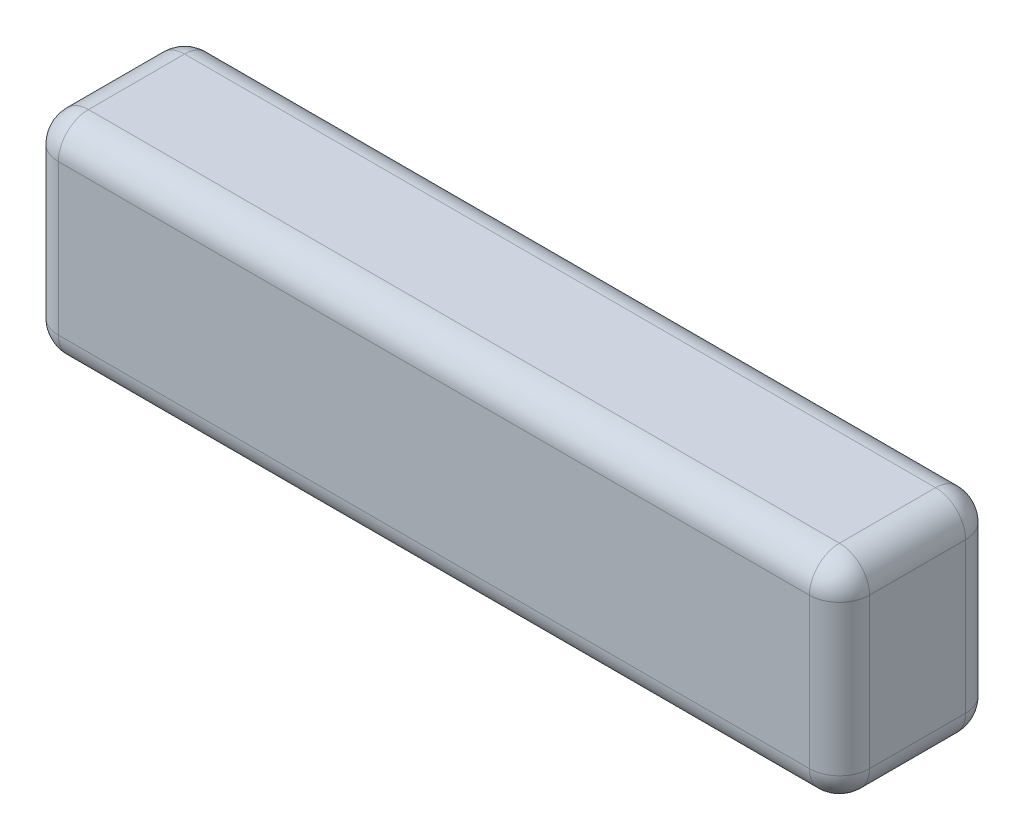
from build123d import *

# Parameters (mm, degrees)
SKETCH1_W           = 135
SKETCH1_H           = 35
BOSS_EXTRUDE1_DEPTH = 26
FILLET1_R           = 5


with BuildPart() as part:
    # Sketch1 → Boss-Extrude1 (new body)
    with BuildSketch(Plane.XY):
        with Locations((67.5, 17.5)):
            Rectangle(SKETCH1_W, SKETCH1_H)
    extrude(amount=BOSS_EXTRUDE1_DEPTH)

    # Fillet1
    fillet1_edges = [part.edges().sort_by_distance(p)[0] for p in [
        (67.5, 35, 26),
        (0, 17.5, 26),
        (67.5, 0, 26),
        (0, 17.5, 0),
        (67.5, 35, 0),
        (135, 17.5, 0),
        (67.5, 0, 0),
        (135, 17.5, 26),
        (0, 0, 13),
        (0, 35, 13),
        (135, 35, 13),
        (135, 0, 13),
    ]]
    fillet(fillet1_edges, radius=FILLET1_R)


solid = part.part
